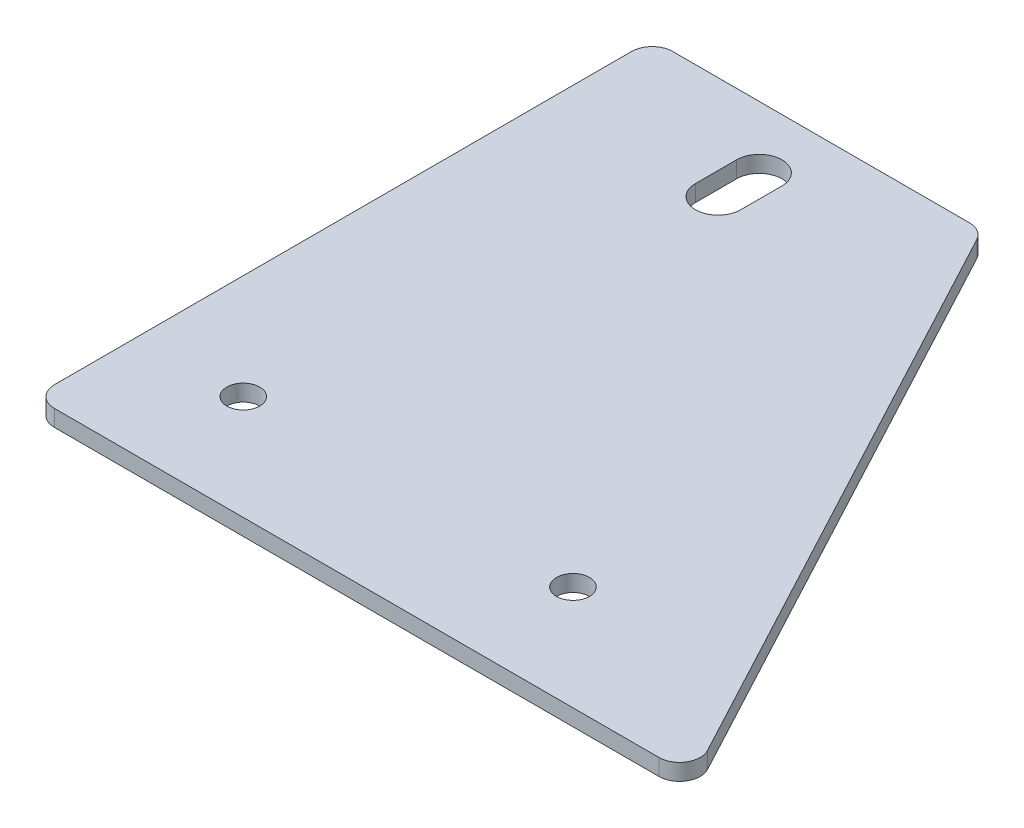
from build123d import *

# Parameters (mm, degrees)
BOSS_EXTRUDE1_DEPTH = 4
SKETCH3_R           = 4
CUT_EXTRUDE1_DEPTH  = 5
FILLET1_R           = 5


with BuildPart() as part:
    # Sketch2 → Boss-Extrude1 (new body)
    with BuildSketch(Plane(origin=(0, 0, 0), x_dir=(1, 0, 0), z_dir=(0, 1, 0))):
        with BuildLine():
            Line((-41, 0), (110.666666667, 0))
            ThreePointArc((110.666666667, 0), (114.954131295, 2.427521223), (115.078431373, 7.352941176))
            Line((115.078431373, 7.352941176), (40.411764706, 147.352941176))
            ThreePointArc((40.411764706, 147.352941176), (38.572478777, 149.287464629), (36, 150))
            Line((36, 150), (-36, 150))
            ThreePointArc((-36, 150), (-39.535533906, 148.535533906), (-41, 145))
            Line((-41, 145), (-41, 0))
        make_face()
    extrude(amount=BOSS_EXTRUDE1_DEPTH)

    # Sketch3 → Cut-Extrude1 (cut, through all)
    with BuildSketch(Plane(origin=(0, 4, 0), x_dir=(1, 0, 0), z_dir=(0, 1, 0))):
        with Locations((-15.6, 25.4)):
            Circle(SKETCH3_R)
        with Locations((64.4, 25.4)):
            Circle(SKETCH3_R)
        with BuildLine():
            Line((5.5, 135), (5.5, 125))
            ThreePointArc((5.5, 125), (0, 119.5), (-5.5, 125))
            Line((-5.5, 125), (-5.5, 135))
            ThreePointArc((-5.5, 135), (0, 140.5), (5.5, 135))
        make_face()
    extrude(amount=-CUT_EXTRUDE1_DEPTH, mode=Mode.SUBTRACT)

    # Fillet1
    fillet1_edges = [part.edges().sort_by_distance(p)[0] for p in [
        (-41, 2, 0),
    ]]
    fillet(fillet1_edges, radius=FILLET1_R)


solid = part.part
